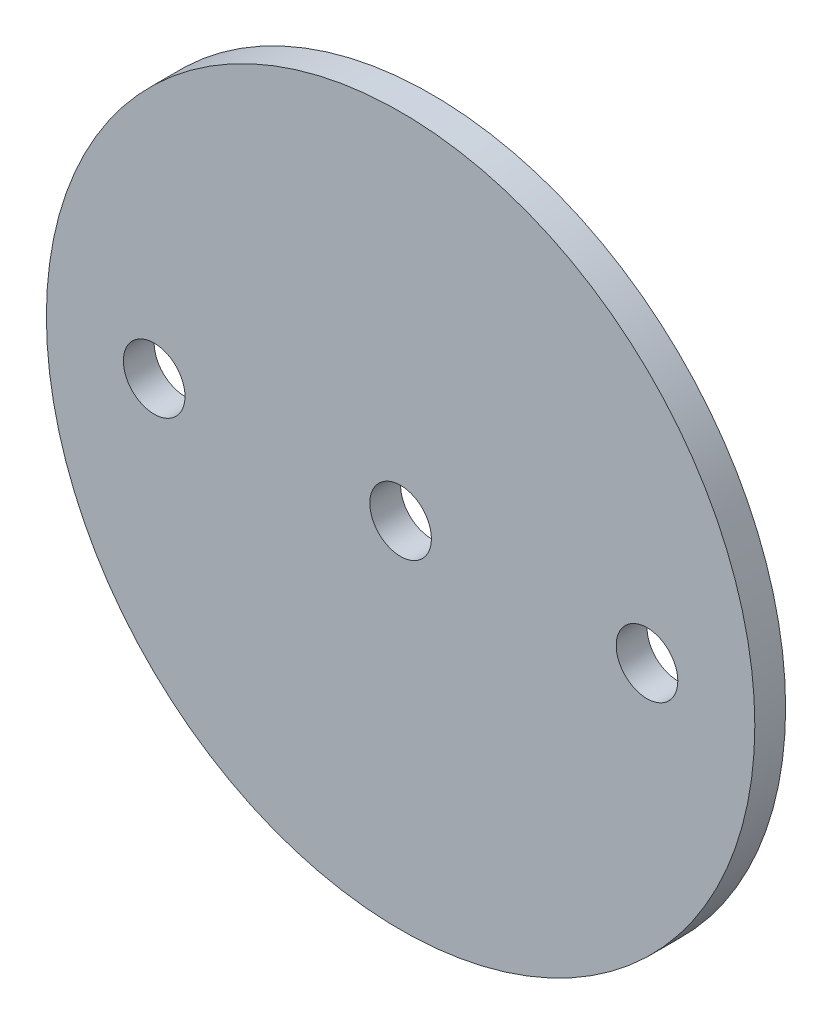
from build123d import *

# Parameters (mm, degrees)
SKETCH1_R                   = 36.5125
BOSS_EXTRUDE1_DEPTH         = 1.5875
F_1_4_0_25_DIAMETER_HOLE1_D = 6.35


with BuildPart() as part:
    # Sketch1 → Boss-Extrude1 (new body, symmetric)
    with BuildSketch(Plane.XY):
        Circle(SKETCH1_R)
    extrude(amount=BOSS_EXTRUDE1_DEPTH, both=True)

    # 1/4 (0.25) Diameter Hole1 (through all)
    with Locations(Plane.XY.offset(1.5875)):
        with Locations((-25.4, 0), (0, 0), (25.4, 0)):
            Hole(F_1_4_0_25_DIAMETER_HOLE1_D / 2)


solid = part.part
